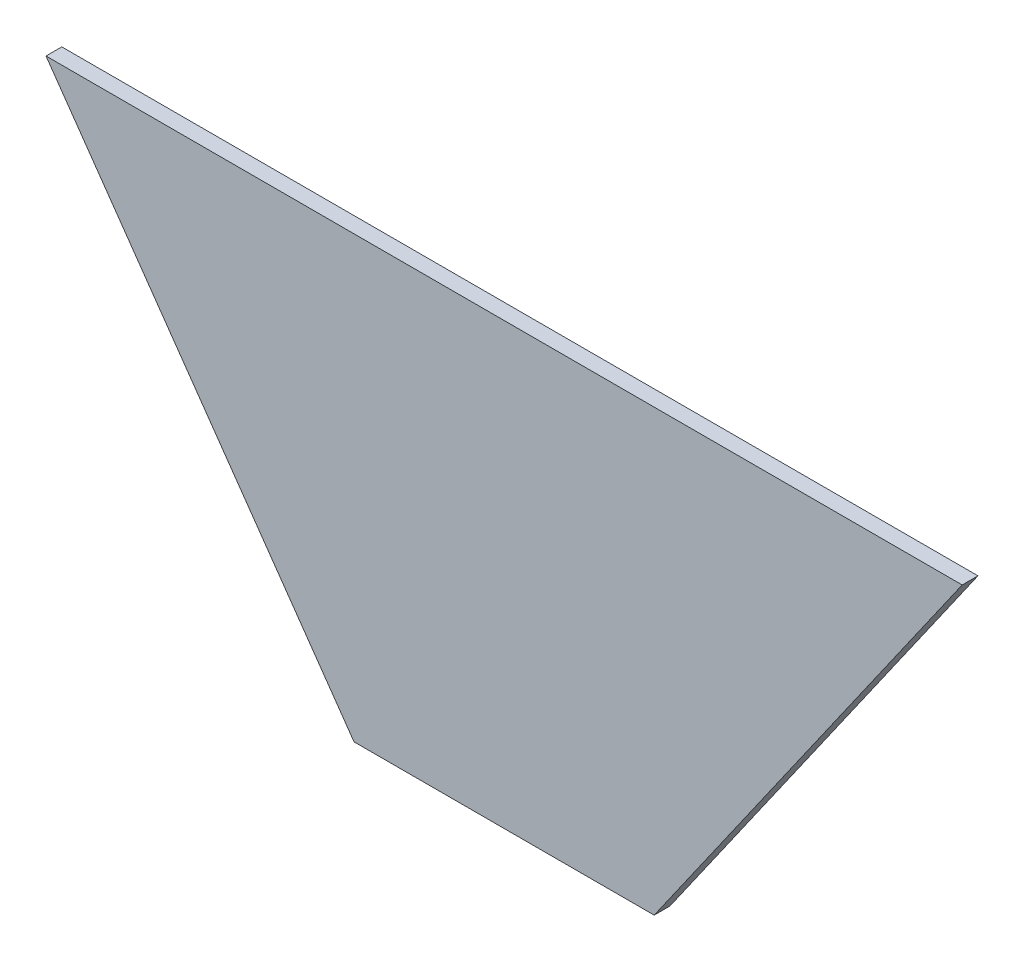
from build123d import *

# Parameters (mm, degrees)
BOSS_EXTRUDE1_DEPTH = 10


with BuildPart() as part:
    # Sketch2 → Boss-Extrude1 (new body)
    with BuildSketch(Plane.XY):
        Polygon((-95, 0), (95, 0), (290, 278.522889544), (-290, 278.522889544), align=None)
    extrude(amount=BOSS_EXTRUDE1_DEPTH)


solid = part.part
